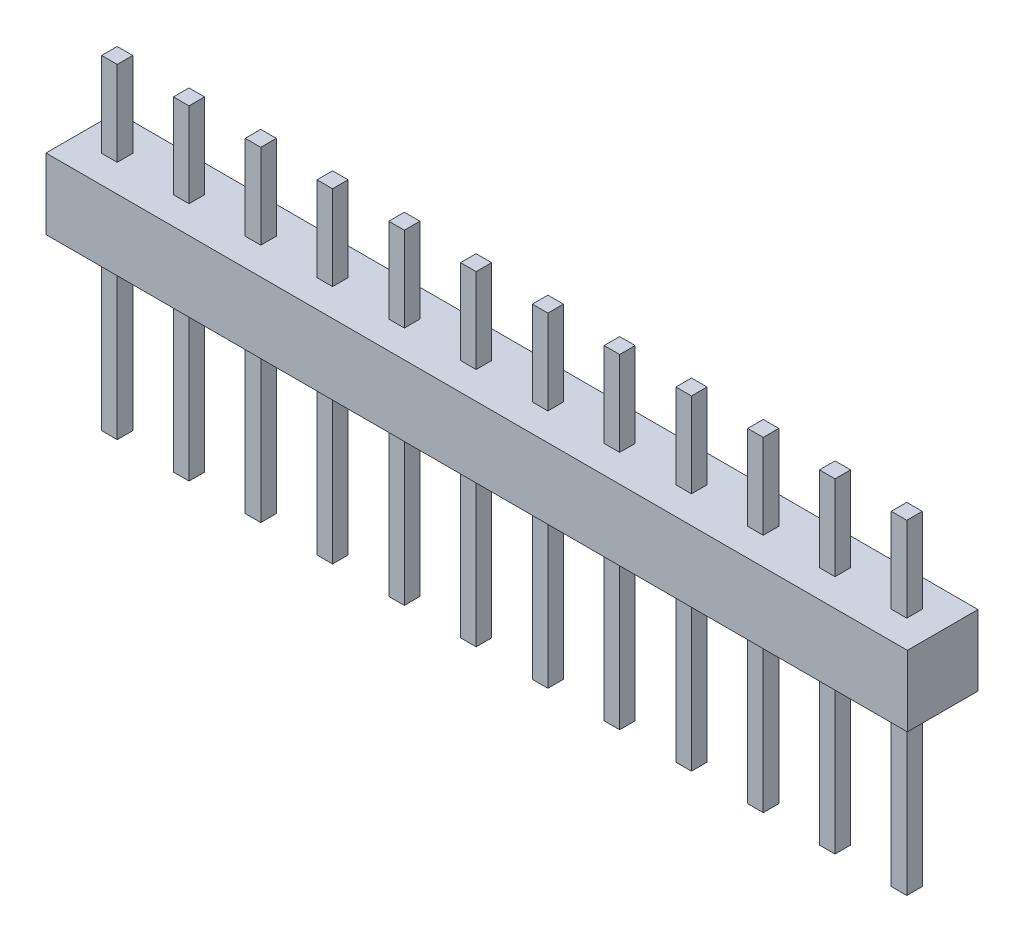
from build123d import *

# Parameters (mm, degrees)
SKETCH1_W              = 30.48
SKETCH1_H              = 2.5
BOSS_EXTRUDE1_DEPTH    = 1.25
SKETCH2_W              = 0.55
SKETCH2_H              = 0.55
BOSS_EXTRUDE2_DEPTH    = 6
BOSS_EXTRUDE2_2_DEPTH  = 6
BOSS_EXTRUDE2_3_DEPTH  = 6
BOSS_EXTRUDE2_4_DEPTH  = 6
BOSS_EXTRUDE2_5_DEPTH  = 6
BOSS_EXTRUDE2_6_DEPTH  = 6
BOSS_EXTRUDE2_7_DEPTH  = 6
BOSS_EXTRUDE2_8_DEPTH  = 6
BOSS_EXTRUDE2_9_DEPTH  = 6
BOSS_EXTRUDE2_10_DEPTH = 6
BOSS_EXTRUDE2_11_DEPTH = 6
BOSS_EXTRUDE2_12_DEPTH = 6
SKETCH2_2_W            = 0.55
SKETCH2_2_H            = 0.55
BOSS_EXTRUDE3_DEPTH    = 5.5
BOSS_EXTRUDE3_2_DEPTH  = 5.5
BOSS_EXTRUDE3_3_DEPTH  = 5.5
BOSS_EXTRUDE3_4_DEPTH  = 5.5
BOSS_EXTRUDE3_5_DEPTH  = 5.5
BOSS_EXTRUDE3_6_DEPTH  = 5.5
BOSS_EXTRUDE3_7_DEPTH  = 5.5
BOSS_EXTRUDE3_8_DEPTH  = 5.5
BOSS_EXTRUDE3_9_DEPTH  = 5.5
BOSS_EXTRUDE3_10_DEPTH = 5.5
BOSS_EXTRUDE3_11_DEPTH = 5.5
BOSS_EXTRUDE3_12_DEPTH = 5.5


with BuildPart() as part:
    # Sketch1 → Boss-Extrude1 (new body, symmetric)
    with BuildSketch(Plane.XY):
        with Locations((15.24, 1.25)):
            Rectangle(SKETCH1_W, SKETCH1_H)
    extrude(amount=BOSS_EXTRUDE1_DEPTH, both=True)


with BuildPart() as body_2:
    # Sketch2 → Boss-Extrude2 (new body)
    with BuildSketch(Plane.XZ):
        with Locations((3.81, 0)):
            Rectangle(SKETCH2_W, SKETCH2_H)
    extrude(amount=BOSS_EXTRUDE2_DEPTH)


with BuildPart() as body_3:
    # Sketch2 → Boss-Extrude2 2 (new body)
    with BuildSketch(Plane.XZ):
        with Locations((1.27, 0)):
            Rectangle(SKETCH2_W, SKETCH2_H)
    extrude(amount=BOSS_EXTRUDE2_2_DEPTH)


with BuildPart() as body_4:
    # Sketch2 → Boss-Extrude2 3 (new body)
    with BuildSketch(Plane.XZ):
        with Locations((6.35, 0)):
            Rectangle(SKETCH2_W, SKETCH2_H)
    extrude(amount=BOSS_EXTRUDE2_3_DEPTH)


with BuildPart() as body_5:
    # Sketch2 → Boss-Extrude2 4 (new body)
    with BuildSketch(Plane.XZ):
        with Locations((8.89, 0)):
            Rectangle(SKETCH2_W, SKETCH2_H)
    extrude(amount=BOSS_EXTRUDE2_4_DEPTH)


with BuildPart() as body_6:
    # Sketch2 → Boss-Extrude2 5 (new body)
    with BuildSketch(Plane.XZ):
        with Locations((11.43, 0)):
            Rectangle(SKETCH2_W, SKETCH2_H)
    extrude(amount=BOSS_EXTRUDE2_5_DEPTH)


with BuildPart() as body_7:
    # Sketch2 → Boss-Extrude2 6 (new body)
    with BuildSketch(Plane.XZ):
        with Locations((13.97, 0)):
            Rectangle(SKETCH2_W, SKETCH2_H)
    extrude(amount=BOSS_EXTRUDE2_6_DEPTH)


with BuildPart() as body_8:
    # Sketch2 → Boss-Extrude2 7 (new body)
    with BuildSketch(Plane.XZ):
        with Locations((16.51, 0)):
            Rectangle(SKETCH2_W, SKETCH2_H)
    extrude(amount=BOSS_EXTRUDE2_7_DEPTH)


with BuildPart() as body_9:
    # Sketch2 → Boss-Extrude2 8 (new body)
    with BuildSketch(Plane.XZ):
        with Locations((19.05, 0)):
            Rectangle(SKETCH2_W, SKETCH2_H)
    extrude(amount=BOSS_EXTRUDE2_8_DEPTH)


with BuildPart() as body_10:
    # Sketch2 → Boss-Extrude2 9 (new body)
    with BuildSketch(Plane.XZ):
        with Locations((21.59, 0)):
            Rectangle(SKETCH2_W, SKETCH2_H)
    extrude(amount=BOSS_EXTRUDE2_9_DEPTH)


with BuildPart() as body_11:
    # Sketch2 → Boss-Extrude2 10 (new body)
    with BuildSketch(Plane.XZ):
        with Locations((24.13, 0)):
            Rectangle(SKETCH2_W, SKETCH2_H)
    extrude(amount=BOSS_EXTRUDE2_10_DEPTH)


with BuildPart() as body_12:
    # Sketch2 → Boss-Extrude2 11 (new body)
    with BuildSketch(Plane.XZ):
        with Locations((26.67, 0)):
            Rectangle(SKETCH2_W, SKETCH2_H)
    extrude(amount=BOSS_EXTRUDE2_11_DEPTH)


with BuildPart() as body_13:
    # Sketch2 → Boss-Extrude2 12 (new body)
    with BuildSketch(Plane.XZ):
        with Locations((29.21, 0)):
            Rectangle(SKETCH2_W, SKETCH2_H)
    extrude(amount=BOSS_EXTRUDE2_12_DEPTH)


with BuildPart() as body_14:
    # Sketch2_2 → Boss-Extrude3 (new body)
    with BuildSketch(Plane.XZ):
        with Locations((3.81, 0)):
            Rectangle(SKETCH2_2_W, SKETCH2_2_H)
    extrude(amount=-BOSS_EXTRUDE3_DEPTH)


with BuildPart() as body_15:
    # Sketch2_2 → Boss-Extrude3 2 (new body)
    with BuildSketch(Plane.XZ):
        with Locations((1.27, 0)):
            Rectangle(SKETCH2_2_W, SKETCH2_2_H)
    extrude(amount=-BOSS_EXTRUDE3_2_DEPTH)


with BuildPart() as body_16:
    # Sketch2_2 → Boss-Extrude3 3 (new body)
    with BuildSketch(Plane.XZ):
        with Locations((6.35, 0)):
            Rectangle(SKETCH2_2_W, SKETCH2_2_H)
    extrude(amount=-BOSS_EXTRUDE3_3_DEPTH)


with BuildPart() as body_17:
    # Sketch2_2 → Boss-Extrude3 4 (new body)
    with BuildSketch(Plane.XZ):
        with Locations((8.89, 0)):
            Rectangle(SKETCH2_2_W, SKETCH2_2_H)
    extrude(amount=-BOSS_EXTRUDE3_4_DEPTH)


with BuildPart() as body_18:
    # Sketch2_2 → Boss-Extrude3 5 (new body)
    with BuildSketch(Plane.XZ):
        with Locations((11.43, 0)):
            Rectangle(SKETCH2_2_W, SKETCH2_2_H)
    extrude(amount=-BOSS_EXTRUDE3_5_DEPTH)


with BuildPart() as body_19:
    # Sketch2_2 → Boss-Extrude3 6 (new body)
    with BuildSketch(Plane.XZ):
        with Locations((13.97, 0)):
            Rectangle(SKETCH2_2_W, SKETCH2_2_H)
    extrude(amount=-BOSS_EXTRUDE3_6_DEPTH)


with BuildPart() as body_20:
    # Sketch2_2 → Boss-Extrude3 7 (new body)
    with BuildSketch(Plane.XZ):
        with Locations((16.51, 0)):
            Rectangle(SKETCH2_2_W, SKETCH2_2_H)
    extrude(amount=-BOSS_EXTRUDE3_7_DEPTH)


with BuildPart() as body_21:
    # Sketch2_2 → Boss-Extrude3 8 (new body)
    with BuildSketch(Plane.XZ):
        with Locations((19.05, 0)):
            Rectangle(SKETCH2_2_W, SKETCH2_2_H)
    extrude(amount=-BOSS_EXTRUDE3_8_DEPTH)


with BuildPart() as body_22:
    # Sketch2_2 → Boss-Extrude3 9 (new body)
    with BuildSketch(Plane.XZ):
        with Locations((21.59, 0)):
            Rectangle(SKETCH2_2_W, SKETCH2_2_H)
    extrude(amount=-BOSS_EXTRUDE3_9_DEPTH)


with BuildPart() as body_23:
    # Sketch2_2 → Boss-Extrude3 10 (new body)
    with BuildSketch(Plane.XZ):
        with Locations((24.13, 0)):
            Rectangle(SKETCH2_2_W, SKETCH2_2_H)
    extrude(amount=-BOSS_EXTRUDE3_10_DEPTH)


with BuildPart() as body_24:
    # Sketch2_2 → Boss-Extrude3 11 (new body)
    with BuildSketch(Plane.XZ):
        with Locations((26.67, 0)):
            Rectangle(SKETCH2_2_W, SKETCH2_2_H)
    extrude(amount=-BOSS_EXTRUDE3_11_DEPTH)


with BuildPart() as body_25:
    # Sketch2_2 → Boss-Extrude3 12 (new body)
    with BuildSketch(Plane.XZ):
        with Locations((29.21, 0)):
            Rectangle(SKETCH2_2_W, SKETCH2_2_H)
    extrude(amount=-BOSS_EXTRUDE3_12_DEPTH)


solid = Compound([part.part, body_2.part, body_3.part, body_4.part, body_5.part, body_6.part, body_7.part, body_8.part, body_9.part, body_10.part, body_11.part, body_12.part, body_13.part, body_14.part, body_15.part, body_16.part, body_17.part, body_18.part, body_19.part, body_20.part, body_21.part, body_22.part, body_23.part, body_24.part, body_25.part])
